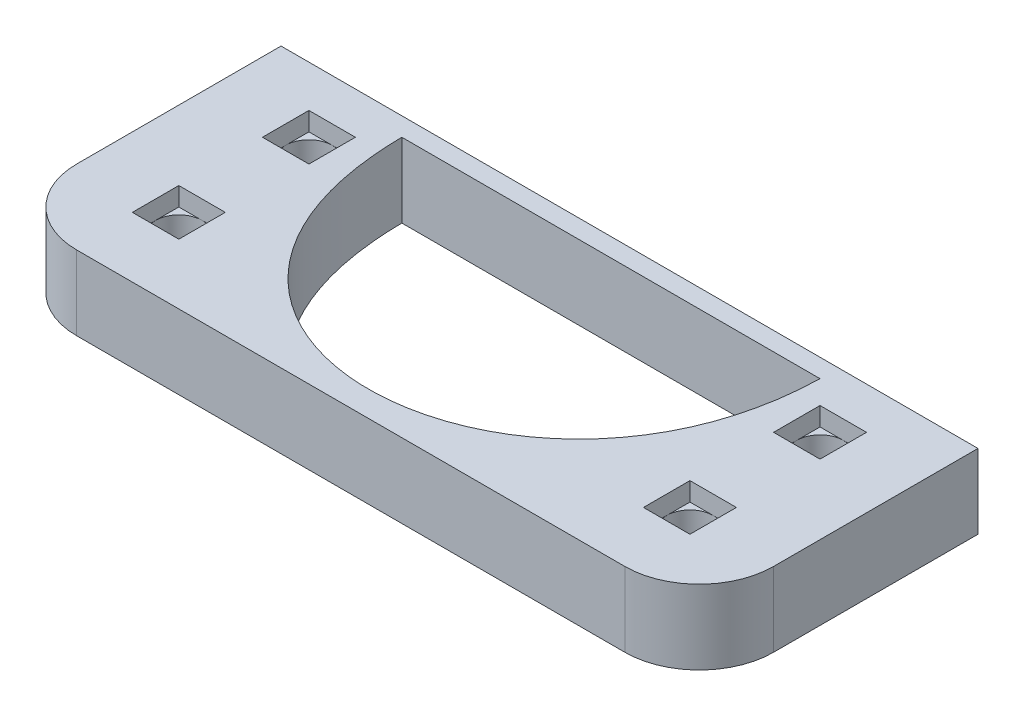
from build123d import *

# Parameters (mm, degrees)
SKETCH1_W           = 75
SKETCH1_H           = 30
BOSS_EXTRUDE1_DEPTH = 8
SKETCH2_R           = 2.5
CUT_EXTRUDE1_DEPTH  = 82.172655494
CUT_EXTRUDE2_DEPTH  = 2
FILLET1_R           = 8
SKETCH3_R           = 1.75
CUT_EXTRUDE3_DEPTH  = 25


with BuildPart() as part:
    # Sketch1 → Boss-Extrude1 (new body)
    with BuildSketch(Plane(origin=(0, 0, 0), x_dir=(1, 0, 0), z_dir=(0, 1, 0))):
        with Locations((37.5, 15)):
            Rectangle(SKETCH1_W, SKETCH1_H)
    extrude(amount=BOSS_EXTRUDE1_DEPTH)

    # Sketch2 → Cut-Extrude1 (cut, through all)
    with BuildSketch(Plane(origin=(0, 8, 0), x_dir=(1, 0, 0), z_dir=(0, 1, 0))):
        with Locations((10, 23)):
            Circle(SKETCH2_R)
        with Locations((10, 9)):
            Circle(SKETCH2_R)
        with Locations((65, 23)):
            Circle(SKETCH2_R)
        with Locations((65, 9)):
            Circle(SKETCH2_R)
        with BuildLine():
            Line((15, 28), (60, 28))
            add(Edge.make_bspline(
                [(60, 28), (59.263620849, -4.332136717), (15.33607355, -7.019589548), (15, 28)],
                knots=[0, 0, 0, 0, 1, 1, 1, 1], degree=3))
        make_face()
    extrude(amount=-CUT_EXTRUDE1_DEPTH, mode=Mode.SUBTRACT)

    # Sketch2_3 → Cut-Extrude2 (cut)
    with BuildSketch(Plane(origin=(0, 8, 0), x_dir=(1, 0, 0), z_dir=(0, 1, 0))):
        with BuildLine():
            Line((12.5, 23), (12.5, 25.5))
            Line((12.5, 25.5), (10, 25.5))
            ThreePointArc((10, 25.5), (11.767766953, 24.767766953), (12.5, 23))
        make_face()
        with BuildLine():
            ThreePointArc((7.5, 23), (8.232233047, 24.767766953), (10, 25.5))
            Line((10, 25.5), (7.5, 25.5))
            Line((7.5, 25.5), (7.5, 23))
        make_face()
        with BuildLine():
            Line((12.5, 20.5), (12.5, 23))
            ThreePointArc((12.5, 23), (11.767766953, 21.232233047), (10, 20.5))
            Line((10, 20.5), (12.5, 20.5))
        make_face()
        with BuildLine():
            ThreePointArc((10, 20.5), (8.232233047, 21.232233047), (7.5, 23))
            Line((7.5, 23), (7.5, 20.5))
            Line((7.5, 20.5), (10, 20.5))
        make_face()
        with BuildLine():
            Line((12.5, 9), (12.5, 11.5))
            Line((12.5, 11.5), (10, 11.5))
            ThreePointArc((10, 11.5), (11.767766953, 10.767766953), (12.5, 9))
        make_face()
        with BuildLine():
            ThreePointArc((7.5, 9), (8.232233047, 10.767766953), (10, 11.5))
            Line((10, 11.5), (7.5, 11.5))
            Line((7.5, 11.5), (7.5, 9))
        make_face()
        with BuildLine():
            Line((12.5, 6.5), (12.5, 9))
            ThreePointArc((12.5, 9), (11.767766965, 7.232233059), (10.000000035, 6.5))
            Line((10.000000035, 6.5), (12.5, 6.5))
        make_face()
        with BuildLine():
            ThreePointArc((10.000000035, 6.5), (8.232233059, 7.232233035), (7.5, 9))
            Line((7.5, 9), (7.5, 6.5))
            Line((7.5, 6.5), (10.000000035, 6.5))
        make_face()
        with BuildLine():
            Line((65, 11.5), (62.5, 11.5))
            Line((62.5, 11.5), (62.5, 9))
            ThreePointArc((62.5, 9), (63.232233047, 10.767766953), (65, 11.5))
        make_face()
        with BuildLine():
            Line((67.5, 11.5), (65, 11.5))
            ThreePointArc((65, 11.5), (66.767766953, 10.767766953), (67.5, 9))
            Line((67.5, 9), (67.5, 11.5))
        make_face()
        with BuildLine():
            ThreePointArc((65, 6.5), (63.232233047, 7.232233047), (62.5, 9))
            Line((62.5, 9), (62.5, 6.5))
            Line((62.5, 6.5), (65, 6.5))
        make_face()
        with BuildLine():
            Line((67.5, 6.5), (67.5, 9))
            ThreePointArc((67.5, 9), (66.767766953, 7.232233047), (65, 6.5))
            Line((65, 6.5), (67.5, 6.5))
        make_face()
        with BuildLine():
            Line((65, 25.5), (62.5, 25.5))
            Line((62.5, 25.5), (62.5, 23))
            ThreePointArc((62.5, 23), (63.232233047, 24.767766953), (65, 25.5))
        make_face()
        with BuildLine():
            Line((67.5, 25.5), (65, 25.5))
            ThreePointArc((65, 25.5), (66.767766953, 24.767766953), (67.5, 23))
            Line((67.5, 23), (67.5, 25.5))
        make_face()
        with BuildLine():
            ThreePointArc((65, 20.5), (63.232233047, 21.232233047), (62.5, 23))
            Line((62.5, 23), (62.5, 20.5))
            Line((62.5, 20.5), (65, 20.5))
        make_face()
        with BuildLine():
            Line((67.5, 20.5), (67.5, 23))
            ThreePointArc((67.5, 23), (66.767766953, 21.232233047), (65, 20.5))
            Line((65, 20.5), (67.5, 20.5))
        make_face()
    extrude(amount=-CUT_EXTRUDE2_DEPTH, mode=Mode.SUBTRACT)

    # Fillet1
    fillet1_edges = [part.edges().sort_by_distance(p)[0] for p in [
        (75, 4, 0),
        (0, 4, 0),
    ]]
    fillet(fillet1_edges, radius=FILLET1_R)

    # Sketch3 → Cut-Extrude3 (cut)
    with BuildSketch(Plane(origin=(0, 0, -30), x_dir=(-1, 0, 0), z_dir=(0, 0, -1))):
        with Locations((-4, 4)):
            Circle(SKETCH3_R)
        with Locations((-71, 4)):
            Circle(SKETCH3_R)
    extrude(amount=-CUT_EXTRUDE3_DEPTH, mode=Mode.SUBTRACT)


solid = part.part
